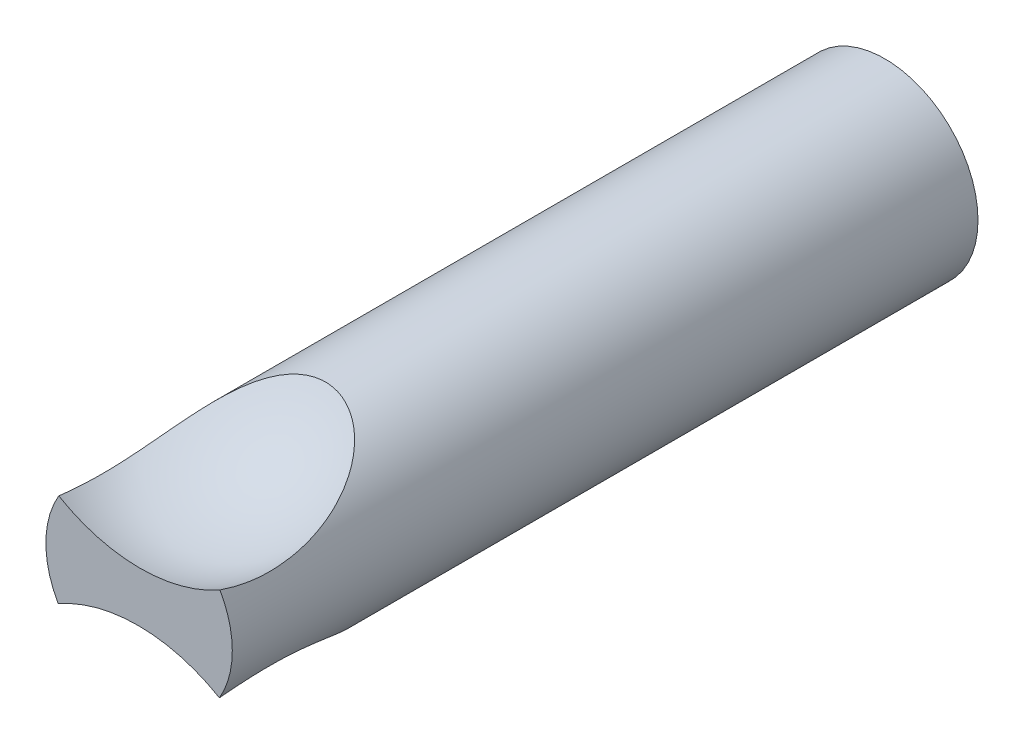
from build123d import *

# Parameters (mm, degrees)
SKETCH1_W = 12.7
SKETCH1_H = 101.6


with BuildPart() as part:
    # Sketch1 → Revolve1 (revolve)
    with BuildSketch(Plane(origin=(0, 0, 0), x_dir=(1, 0, 0), z_dir=(0, 1, 0))):
        with Locations((6.35, 50.8)):
            Rectangle(SKETCH1_W, SKETCH1_H)
    revolve(axis=Axis((0, 0, 0), (0, 0, -1)))

    # Sketch5 → Cut-Revolve1 (revolve, cut)
    with BuildSketch(Plane(origin=(0, 25.4, 0), x_dir=(-1, 0, 0), z_dir=(0, -1, 0))):
        with BuildLine():
            Line((22.718491956, 6.35), (-23.001508044, 6.35))
            ThreePointArc((-23.001508044, 6.35), (-0.141508044, -16.51), (22.718491956, 6.35))
        make_face()
    revolve(axis=Axis((-22.718491956, 25.4, -6.35), (1, 0, 0)), mode=Mode.SUBTRACT)

    # Sketch6 → Cut-Revolve2 (revolve, cut)
    with BuildSketch(Plane(origin=(0, -25.4, 0), x_dir=(1, 0, 0), z_dir=(0, 1, 0))):
        with BuildLine():
            Line((22.718491956, 6.35), (-23.001508044, 6.35))
            ThreePointArc((-23.001508044, 6.35), (-0.141508044, -16.51), (22.718491956, 6.35))
        make_face()
    revolve(axis=Axis((22.718491956, -25.4, -6.35), (-1, 0, 0)), mode=Mode.SUBTRACT)


solid = part.part
